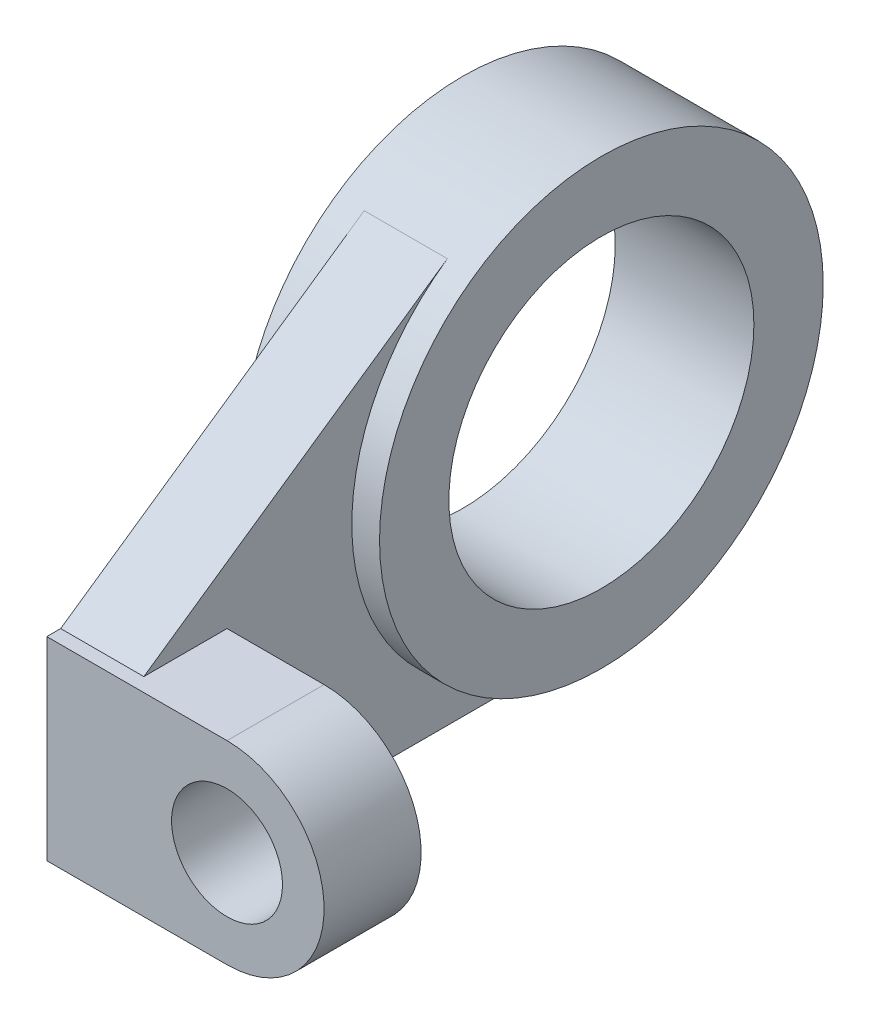
from build123d import *

# Parameters (mm, degrees)
SKETCH1_R           = 34.925
BOSS_EXTRUDE1_DEPTH = 9.525
SKETCH1_3_R         = 34.925
BOSS_EXTRUDE2_DEPTH = 15.875
SKETCH2_W           = 22.225
SKETCH2_H           = 44.45
BOSS_EXTRUDE3_DEPTH = 50.8
SKETCH3_R           = 12.7
CUT_EXTRUDE1_DEPTH  = 172.596927784


with BuildPart() as part:
    # Sketch1 → Boss-Extrude1 (new, symmetric)
    with BuildSketch(Plane(origin=(0, 0, 0), x_dir=(0, 0, -1), z_dir=(1, 0, 0))):
        with BuildLine():
            Line((-101.6, -50.8), (0, -50.8))
            ThreePointArc((0, -50.8), (48.489607735, 15.145888606), (-28.914102256, 41.768584974))
            Line((-28.914102256, 41.768584974), (-98.425, -6.35))
            Line((-98.425, -6.35), (-101.6, -6.35))
            Line((-101.6, -6.35), (-101.6, -50.8))
        make_face()
        Circle(SKETCH1_R, mode=Mode.SUBTRACT)
    extrude(amount=BOSS_EXTRUDE1_DEPTH, both=True)

    # Sketch1_3 → Boss-Extrude2 (add, symmetric)
    with BuildSketch(Plane(origin=(0, 0, 0), x_dir=(0, 0, -1), z_dir=(1, 0, 0))):
        with BuildLine():
            ThreePointArc((-28.914102256, 41.768584974), (-48.489607735, -15.145888606), (0, -50.8))
            ThreePointArc((0, -50.8), (35.921024484, -35.921024484), (50.8, 0))
            ThreePointArc((50.8, 0), (23.577569906, 44.997090987), (-28.914102256, 41.768584974))
        make_face()
        Circle(SKETCH1_3_R, mode=Mode.SUBTRACT)
    extrude(amount=BOSS_EXTRUDE2_DEPTH, both=True)

    # Sketch2 → Boss-Extrude3 (add)
    with BuildSketch(Plane(origin=(9.525, 0, 0), x_dir=(0, 0, -1), z_dir=(1, 0, 0))):
        with Locations((-90.4875, -28.575)):
            Rectangle(SKETCH2_W, SKETCH2_H)
    extrude(amount=BOSS_EXTRUDE3_DEPTH)

    # Sketch3 → Cut-Extrude1 (cut, through all)
    with BuildSketch(Plane.XY.offset(101.6)):
        with BuildLine():
            Line((60.325, -50.8), (60.325, -6.35))
            Line((60.325, -6.35), (31.75, -6.35))
            ThreePointArc((31.75, -6.35), (53.975, -28.575), (31.75, -50.8))
            Line((31.75, -50.8), (60.325, -50.8))
        make_face()
        with Locations((31.75, -28.575)):
            Circle(SKETCH3_R)
    extrude(amount=-CUT_EXTRUDE1_DEPTH, mode=Mode.SUBTRACT)


solid = part.part
